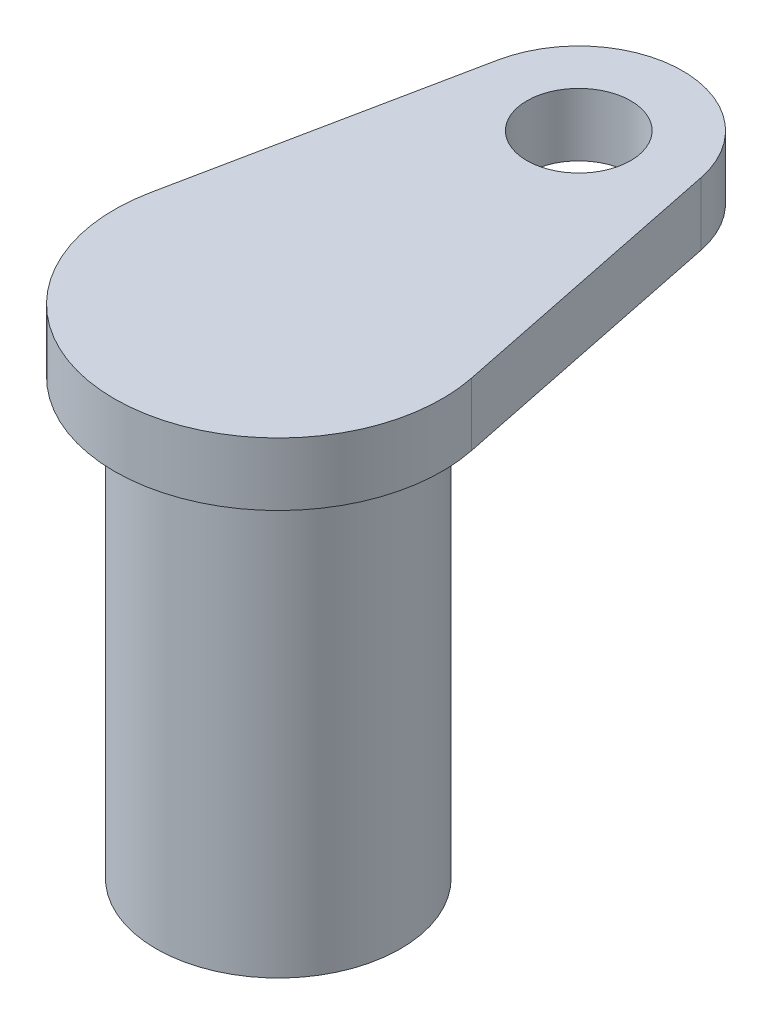
from build123d import *

# Parameters (mm, degrees)
BASE_DEPTH               = 4.6
SKETCH4_R                = 8.95
SENSOR_DEPTH             = 31.8
BOLT_HOLE_M7_CLEARANCE_D = 7.6


with BuildPart() as part:
    # Sketch1 → Base (new body)
    with BuildSketch(Plane(origin=(0, 0, 0), x_dir=(1, 0, 0), z_dir=(0, 1, 0))):
        with BuildLine():
            Line((-11.757550765, 2.4), (-7.446448818, 23.52))
            ThreePointArc((-7.446448818, 23.52), (0, 29.6), (7.446448818, 23.52))
            Line((7.446448818, 23.52), (11.757550765, 2.4))
            ThreePointArc((11.757550765, 2.4), (0, -12), (-11.757550765, 2.4))
        make_face()
    extrude(amount=BASE_DEPTH)

    # Sketch4 → Sensor (add)
    with BuildSketch(Plane(origin=(0, 0, 0), x_dir=(1, 0, 0), z_dir=(0, 1, 0))):
        Circle(SKETCH4_R)
    extrude(amount=-SENSOR_DEPTH)

    # Bolt Hole _M7 Clearance (through all)
    with Locations(Plane(origin=(0, 0, 0), x_dir=(-1, 0, 0), z_dir=(0, -1, 0))):
        with Locations((0, 22)):
            Hole(BOLT_HOLE_M7_CLEARANCE_D / 2)


solid = part.part
